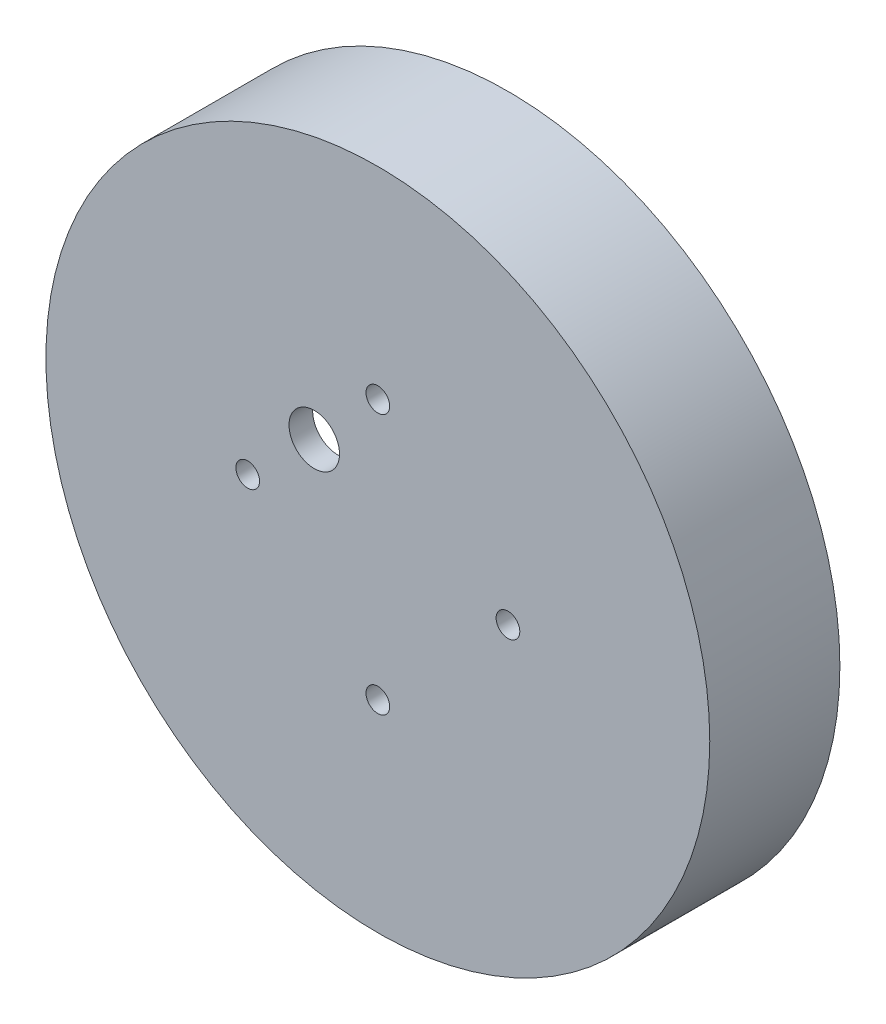
from build123d import *

# Parameters (mm, degrees)
SKETCH1_R               = 42.0875
BOSS_EXTRUDE1_DEPTH     = 16.5
SKETCH2_R               = 38.4875
CUT_EXTRUDE1_DEPTH      = 8.5
SKETCH3_R               = 34.4875
CUT_EXTRUDE2_DEPTH      = 5
SKETCH5_R               = 3.2
CUT_EXTRUDE4_DEPTH      = 1
CUT_EXTRUDE4_DEPTH_BACK = 17.5
CUT_EXTRUDE3_START      = -4
SKETCH4_R               = 1.5
CUT_EXTRUDE3_DEPTH      = 18.5
CIRPATTERN1_COUNT       = 4


with BuildPart() as part:
    # Sketch1 → Boss-Extrude1 (new body)
    with BuildSketch(Plane.XY.offset(-8)):
        Circle(SKETCH1_R)
    extrude(amount=BOSS_EXTRUDE1_DEPTH)

    # Sketch2 → Cut-Extrude1 (cut)
    with BuildSketch(Plane(origin=(0, 0, -8), x_dir=(-1, 0, 0), z_dir=(0, 0, -1))):
        Circle(SKETCH2_R)
    extrude(amount=-CUT_EXTRUDE1_DEPTH, mode=Mode.SUBTRACT)

    # Sketch3 → Cut-Extrude2 (cut)
    with BuildSketch(Plane(origin=(0, 0, 0.5), x_dir=(-1, 0, 0), z_dir=(0, 0, -1))):
        Circle(SKETCH3_R)
    extrude(amount=-CUT_EXTRUDE2_DEPTH, mode=Mode.SUBTRACT)

    # Sketch5 → Cut-Extrude4 (cut, two sides)
    with BuildSketch(Plane.XY.offset(8.5)) as cut_extrude4_sk:
        with Locations((-8.061017306, 8.061017306)):
            Circle(SKETCH5_R)
    extrude(amount=CUT_EXTRUDE4_DEPTH, mode=Mode.SUBTRACT)
    extrude(cut_extrude4_sk.sketch, amount=-CUT_EXTRUDE4_DEPTH_BACK, mode=Mode.SUBTRACT)

    # Sketch4 → Cut-Extrude3 (cut)
    with BuildSketch(Plane(origin=(0, 0, 5.5), x_dir=(-1, 0, 0), z_dir=(0, 0, -1)).offset(CUT_EXTRUDE3_START)):
        with Locations((-16.5, 0)):
            Circle(SKETCH4_R)
    cut_extrude3 = extrude(amount=CUT_EXTRUDE3_DEPTH, mode=Mode.SUBTRACT)

    # CirPattern1: Cut-Extrude3 ×4 about axis
    cirpattern1_axis = Axis((0, 0, 0), (0, 0, 1))
    for i in range(1, CIRPATTERN1_COUNT):
        add(cut_extrude3.rotate(cirpattern1_axis, i * 360 / CIRPATTERN1_COUNT), mode=Mode.SUBTRACT)


solid = part.part
